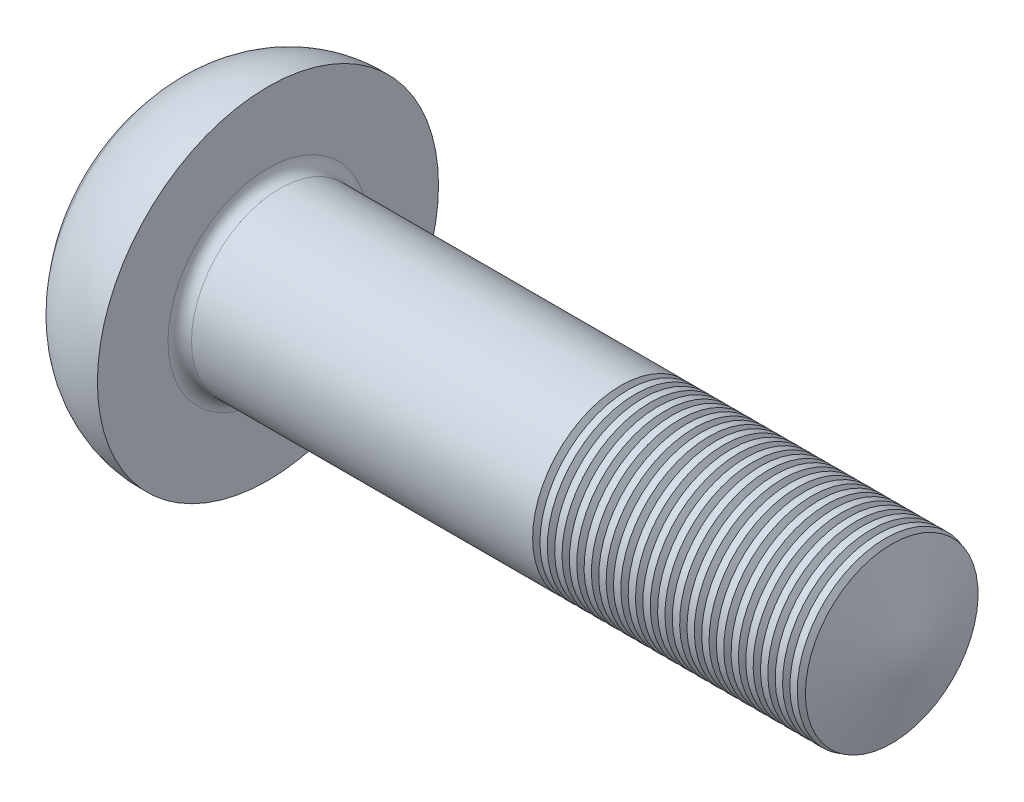
from build123d import *

# Parameters (mm, degrees)
FILLET2_R        = 0.2
LPATTERN10_COUNT = 20
LPATTERN10_PITCH = 0.25


with BuildPart() as part:
    # Sketch1 → Revolve1 (revolve)
    with BuildSketch(Plane(origin=(0, 0, 0), x_dir=(1, 0, 0), z_dir=(0, 1, 0))):
        with BuildLine():
            Line((2.37, 1.5), (13.37, 1.5))
            Line((13.37, 1.5), (13.37, 0))
            Line((13.37, 0), (0, 0))
            ThreePointArc((0, 0), (0.224879408, 1.215980768), (0.869770135, 2.271109163))
            ThreePointArc((0.869770135, 2.271109163), (1.549177667, 2.754228297), (2.37, 2.9))
            Line((2.37, 2.9), (2.37, 1.5))
        make_face()
    revolve(axis=Axis((-13.629268293, 0, 0), (1, 0, 0)))

    # Fillet2
    fillet2_edges = [part.edges().sort_by_distance(p)[0] for p in [
        (2.37, 0, 1.5),
    ]]
    fillet(fillet2_edges, radius=FILLET2_R)

    # Sketch4 → Cut-Revolve1 (revolve, cut)
    with BuildSketch(Plane(origin=(0, 0, 0), x_dir=(1, 0, 0), z_dir=(0, 1, 0))):
        Polygon((14.103454633, 0), (14.103454633, 21), (7.743066959, 21), (13.37, 0), align=None)
    revolve(axis=Axis((4.782773752, 0, 0), (1, 0, 0)), mode=Mode.SUBTRACT)

    # Sketch2 → Cut-Loft1 section 0
    with BuildSketch(Plane(origin=(0, 0, 0), x_dir=(0, 0, -1), z_dir=(1, 0, 0)), mode=Mode.PRIVATE) as cut_loft1_s0:
        Polygon((-0.4625, 0.4625), (-1.85, 0.4625), (-1.85, -0.4625), (-0.4625, -0.4625), (-0.4625, -1.85), (0.4625, -1.85), (0.4625, -0.4625), (1.85, -0.4625), (1.85, 0.4625), (0.4625, 0.4625), (0.4625, 1.85), (-0.4625, 1.85), align=None)
    loft([Vertex(2.62, 0, 0), cut_loft1_s0.sketch], mode=Mode.SUBTRACT)

    # Sketch6 → Cut-Revolve10 (revolve, cut)
    with BuildSketch(Plane.XY):
        Polygon((8.37, 1.7), (8.495, 1.7), (8.495, 1.5), (8.4325, 1.391746825), (8.37, 1.5), align=None)
    cut_revolve10 = revolve(axis=Axis((10.774329131, 0, 0), (-1, 0, 0)), mode=Mode.SUBTRACT)

    # LPattern10: Cut-Revolve10 ×20
    with Locations(*[(i * LPATTERN10_PITCH, 0, 0) for i in range(1, LPATTERN10_COUNT)]):
        add(cut_revolve10, mode=Mode.SUBTRACT)


solid = part.part
